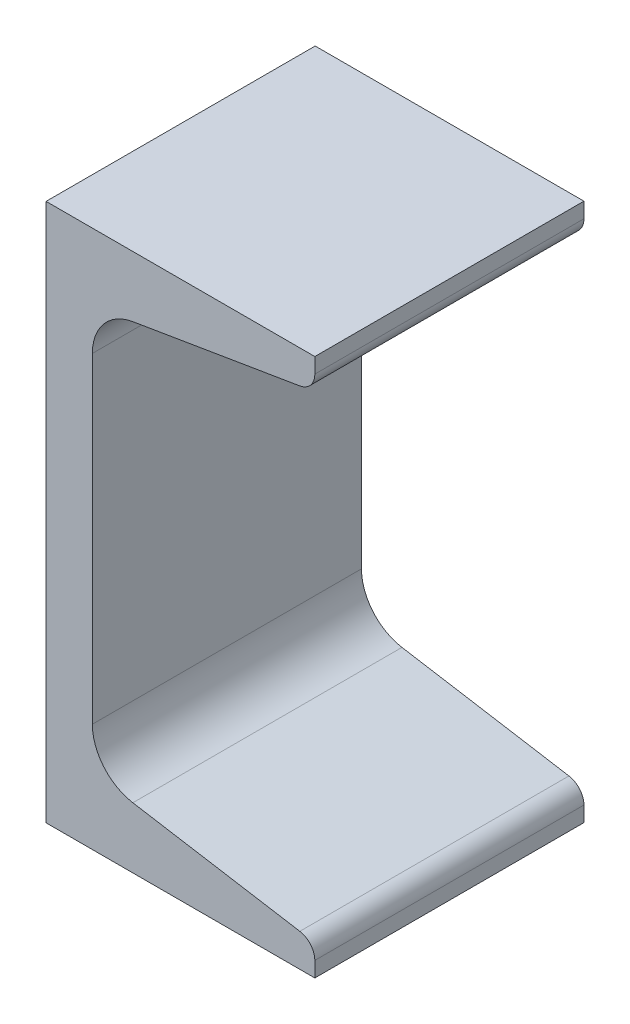
from build123d import *

# Parameters (mm, degrees)
BOSS_EXTRUDE1_DEPTH = 19.05


with BuildPart() as part:
    # Sketch1 → Boss-Extrude1 (new body, symmetric)
    with BuildSketch(Plane.XY):
        with BuildLine():
            Line((0, 0), (0, 76.2))
            Line((0, 76.2), (38.0492, 76.2))
            Line((38.0492, 76.2), (38.0492, 74.042335136))
            ThreePointArc((38.0492, 74.042335136), (37.447280466, 72.400554363), (35.926803066, 71.536899509))
            Line((35.926803066, 71.536899509), (12.283671721, 67.596090157))
            ThreePointArc((12.283671721, 67.596090157), (8.178382741, 65.264222052), (6.5532, 60.831413966))
            Line((6.5532, 60.831413966), (6.5532, 15.368586034))
            ThreePointArc((6.5532, 15.368586034), (8.178382741, 10.935777948), (12.283671721, 8.603909843))
            Line((12.283671721, 8.603909843), (35.926803066, 4.663100491))
            ThreePointArc((35.926803066, 4.663100491), (37.447280466, 3.799445637), (38.0492, 2.157664864))
            Line((38.0492, 2.157664864), (38.0492, 0))
            Line((38.0492, 0), (0, 0))
        make_face()
    extrude(amount=BOSS_EXTRUDE1_DEPTH, both=True)


solid = part.part
